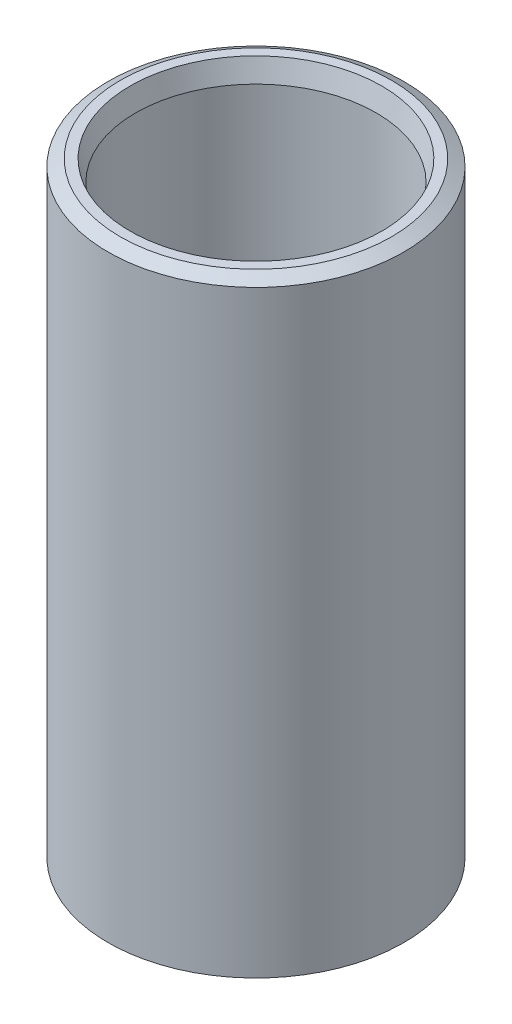
from build123d import *

# Parameters (mm, degrees)
DURCHMESSER_WD_R   = 24.15
DURCHMESSER_WD_R_2 = 19.65
ROHR_DEPTH         = 100


with BuildPart() as part:
    # Durchmesser/ WD → Rohr (new body)
    with BuildSketch(Plane(origin=(0, 0, 0), x_dir=(1, 0, 0), z_dir=(0, 1, 0))):
        with Locations(Location((0, 0, 0), (0, 0, 270))):  # turned: the seam where the file's is
            Circle(DURCHMESSER_WD_R)
        with Locations(Location((0, 0, 0), (0, 0, 270))):  # turned: the seam where the file's is
            Circle(DURCHMESSER_WD_R_2, mode=Mode.SUBTRACT)
    extrude(amount=ROHR_DEPTH)

    # Fase1 → Schweißfase 1 (revolve, cut)
    with BuildSketch(Plane.XY, mode=Mode.PRIVATE) as schwei_fase_1_sk:
        Polygon((24.15, 100), (24.15, 98.845299462), (22.15, 100), align=None)
        Polygon((20.55, 100), (19.65, 100), (19.65, 96.641154273), align=None)
    revolve(schwei_fase_1_sk.sketch.rotate(Axis((0, 0, 0), (0, 1, 0)), 90), axis=Axis((0, 0, 0), (0, 1, 0)), mode=Mode.SUBTRACT)  # turned: the seam where the file's is

    # Fase2 → Schweißfase 2 (revolve, cut)
    with BuildSketch(Plane.XY, mode=Mode.PRIVATE) as schwei_fase_2_sk:
        Polygon((24.15, 0), (24.15, 1.154700538), (22.15, 0), align=None)
        Polygon((20.55, 0), (19.65, 0), (19.65, 3.358845727), align=None)
    revolve(schwei_fase_2_sk.sketch.rotate(Axis((0, 0, 0), (0, 1, 0)), 90), axis=Axis((0, 0, 0), (0, 1, 0)), mode=Mode.SUBTRACT)  # turned: the seam where the file's is


solid = part.part
